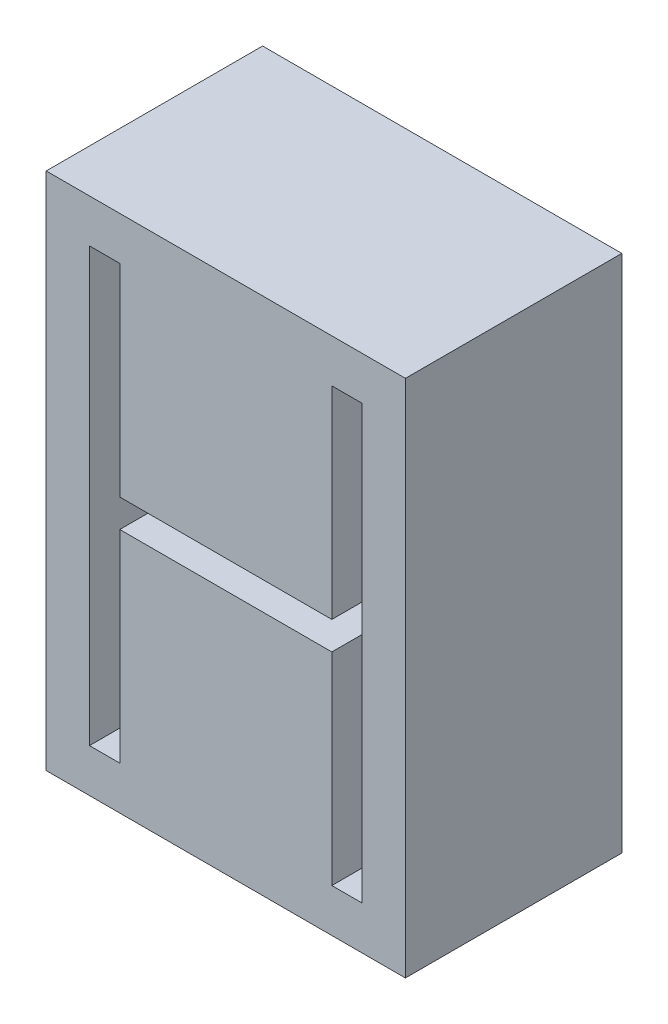
from build123d import *

# Parameters (mm, degrees)
SKETCH1_W           = 16.6
SKETCH1_H           = 24
BOSS_EXTRUDE1_DEPTH = 10


with BuildPart() as part:
    # Sketch1 → Boss-Extrude1 (new body)
    with BuildSketch(Plane.XY):
        Rectangle(SKETCH1_W, SKETCH1_H)
        Polygon((-4.9, 10), (-4.9, 0.65), (4.9, 0.65), (4.9, 10), (6.3, 10), (6.3, -10), (4.9, -10), (4.9, -0.65), (-4.9, -0.65), (-4.9, -10), (-6.3, -10), (-6.3, 10), align=None, mode=Mode.SUBTRACT)
    extrude(amount=BOSS_EXTRUDE1_DEPTH)


solid = part.part
